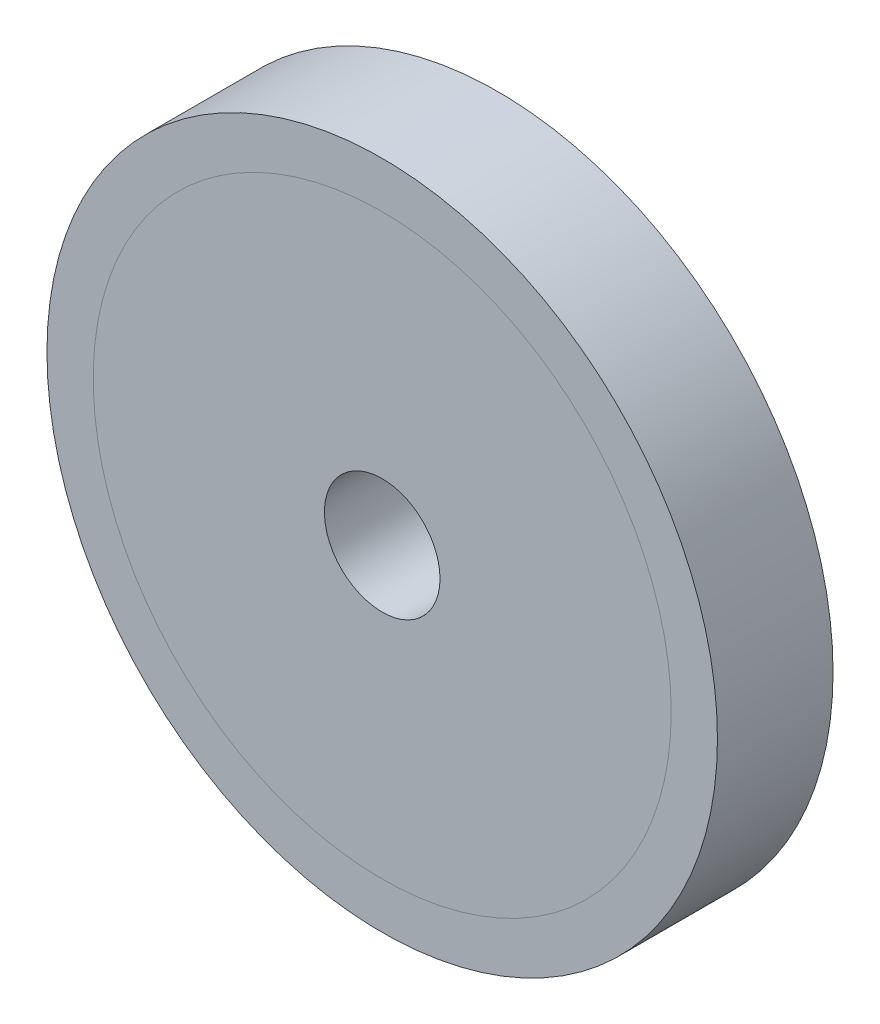
from build123d import *

# Parameters (mm, degrees)
SKETCH1_R           = 5.8
SKETCH1_R_2         = 5
BOSS_EXTRUDE1_DEPTH = 2
SKETCH1_2_R         = 5
BOSS_EXTRUDE2_DEPTH = 2
SKETCH2_R           = 1
CUT_EXTRUDE1_DEPTH  = 2


with BuildPart() as part:
    # Sketch1 → Boss-Extrude1 (new body)
    with BuildSketch(Plane.XY):
        Circle(SKETCH1_R)
        Circle(SKETCH1_R_2, mode=Mode.SUBTRACT)
    extrude(amount=BOSS_EXTRUDE1_DEPTH)


with BuildPart() as body_2:
    # Sketch1_2 → Boss-Extrude2 (new body)
    with BuildSketch(Plane.XY):
        Circle(SKETCH1_2_R)
    extrude(amount=BOSS_EXTRUDE2_DEPTH)

    # Sketch2 → Cut-Extrude1 (cut)
    with BuildSketch(Plane.XY.offset(2)):
        Circle(SKETCH2_R)
    extrude(amount=-CUT_EXTRUDE1_DEPTH, mode=Mode.SUBTRACT)


solid = Compound([part.part, body_2.part])
